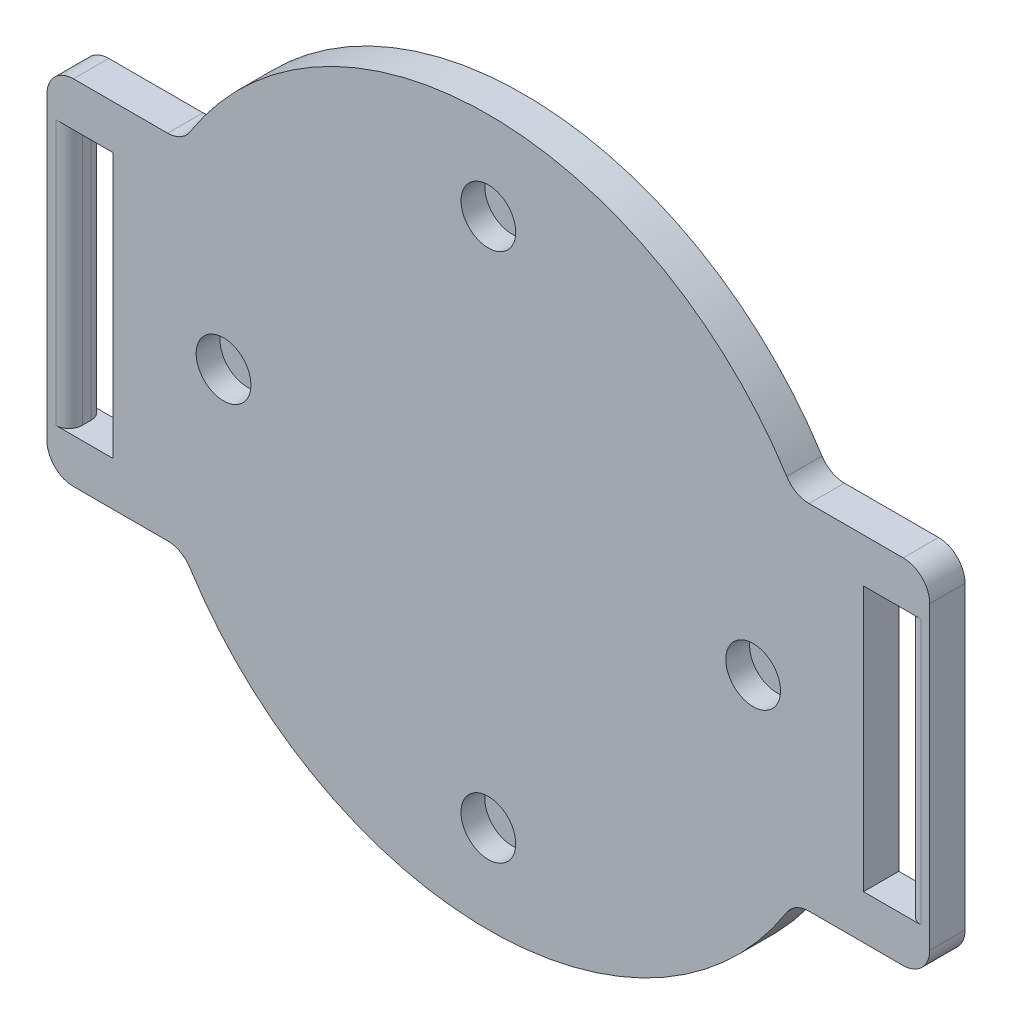
from build123d import *

# Parameters (mm, degrees)
BOSS_EXTRU_1_DEPTH           = 4
ESQUISSE2_R                  = 3.1
ENL_V_MAT_EXTRU_1_DEPTH      = 1
ENL_V_MAT_EXTRU_1_DEPTH_BACK = 2.7
ESQUISSE3_W                  = 5
ESQUISSE3_H                  = 30
ENL_V_MAT_EXTRU_2_DEPTH      = 12.7
CONG_1_R                     = 1.5
CONG_2_R                     = 3
CONG_3_R                     = 3


with BuildPart() as part:
    # Esquisse1 → Boss.-Extru.1 (new body)
    with BuildSketch(Plane.XY):
        with BuildLine():
            Line((-34.641016151, -20), (-50, -20))
            Line((-50, -20), (-50, 20))
            Line((-50, 20), (-34.641016151, 20))
            ThreePointArc((-34.641016151, 20), (0, 40), (34.641016151, 20))
            Line((34.641016151, 20), (50, 20))
            Line((50, 20), (50, -20))
            Line((50, -20), (34.641016151, -20))
            ThreePointArc((34.641016151, -20), (0, -40), (-34.641016151, -20))
        make_face()
    extrude(amount=BOSS_EXTRU_1_DEPTH)

    # Esquisse2 → Enlèv. mat.-Extru.1 (cut, two sides)
    with BuildSketch(Plane.XY.offset(4)) as enl_v_mat_extru_1_sk:
        with Locations((0, 30)):
            Circle(ESQUISSE2_R)
        with Locations((30, 0)):
            Circle(ESQUISSE2_R)
        with Locations((0, -30)):
            Circle(ESQUISSE2_R)
        with Locations((-30, 0)):
            Circle(ESQUISSE2_R)
    extrude(amount=ENL_V_MAT_EXTRU_1_DEPTH, mode=Mode.SUBTRACT)
    extrude(enl_v_mat_extru_1_sk.sketch, amount=-ENL_V_MAT_EXTRU_1_DEPTH_BACK, mode=Mode.SUBTRACT)

    # Esquisse3 → Enlèv. mat.-Extru.2 (cut)
    with BuildSketch(Plane.XY.offset(4)):
        with Locations((-45, 0)):
            Rectangle(ESQUISSE3_W, ESQUISSE3_H)
        with Locations((45, 0)):
            Rectangle(ESQUISSE3_W, ESQUISSE3_H)
    extrude(amount=-ENL_V_MAT_EXTRU_2_DEPTH, mode=Mode.SUBTRACT)

    # Congé1
    cong_1_edges = [part.edges().sort_by_distance(p)[0] for p in [
        (47.5, 0, 0),
        (-47.5, 0, 0),
        (-47.5, 0, 4),
        (47.5, 0, 4),
    ]]
    fillet(cong_1_edges, radius=CONG_1_R)

    # Congé2
    cong_2_edges = [part.edges().sort_by_distance(p)[0] for p in [
        (50, 20, 2),
        (50, -20, 2),
        (-50, -20, 2),
        (-50, 20, 2),
    ]]
    fillet(cong_2_edges, radius=CONG_2_R)

    # Congé3
    cong_3_edges = [part.edges().sort_by_distance(p)[0] for p in [
        (34.641016151, 20, 2),
        (34.641016151, -20, 2),
        (-34.641016151, -20, 2),
        (-34.641016151, 20, 2),
    ]]
    fillet(cong_3_edges, radius=CONG_3_R)


solid = part.part
